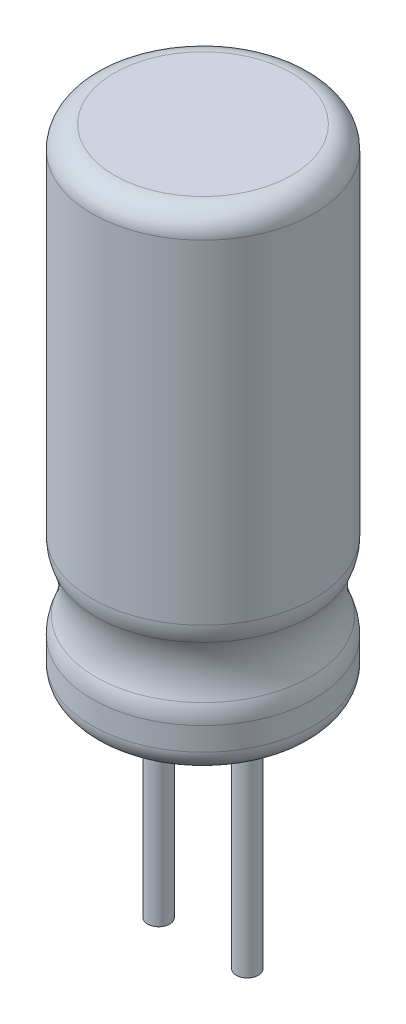
from build123d import *

# Parameters (mm, degrees)
SKETCH1_R           = 2.5
BOSS_EXTRUDE1_DEPTH = 11
SKETCH2_R           = 0.25
BOSS_EXTRUDE2_DEPTH = 5
SKETCH3_R           = 1.5
FILLET1_R           = 1
FILLET2_R           = 0.5
FILLET3_R           = 0.5


with BuildPart() as part:
    # Sketch1 → Boss-Extrude1 (new body)
    with BuildSketch(Plane(origin=(0, 0, 0), x_dir=(1, 0, 0), z_dir=(0, 1, 0))):
        Circle(SKETCH1_R)
    extrude(amount=BOSS_EXTRUDE1_DEPTH)

    # Sketch2 → Boss-Extrude2 (add)
    with BuildSketch(Plane.XZ):
        with Locations((1, 0)):
            Circle(SKETCH2_R)
        with Locations((-1, 0)):
            Circle(SKETCH2_R)
    extrude(amount=BOSS_EXTRUDE2_DEPTH)

    # Sketch3 → Cut-Revolve1 (revolve, cut)
    with BuildSketch(Plane(origin=(0, 0, 0), x_dir=(0, 0, -1), z_dir=(1, 0, 0))):
        with Locations((3.8, 2)):
            Circle(SKETCH3_R)
    revolve(axis=Axis((0, 21.78154861, 0), (0, -1, 0)), mode=Mode.SUBTRACT)

    # Fillet1
    fillet1_edges = [part.edges().sort_by_distance(p)[0] for p in [
        (-1.767766953, 2.748331477, 1.767766953),
        (-1.767766953, 1.251668523, 1.767766953),
    ]]
    fillet(fillet1_edges, radius=FILLET1_R)

    # Fillet2
    fillet2_edges = [part.edges().sort_by_distance(p)[0] for p in [
        (-2.5, 11, 0),
    ]]
    fillet(fillet2_edges, radius=FILLET2_R)

    # Fillet3
    fillet3_edges = [part.edges().sort_by_distance(p)[0] for p in [
        (-2.5, 0, 0),
    ]]
    fillet(fillet3_edges, radius=FILLET3_R)


solid = part.part
